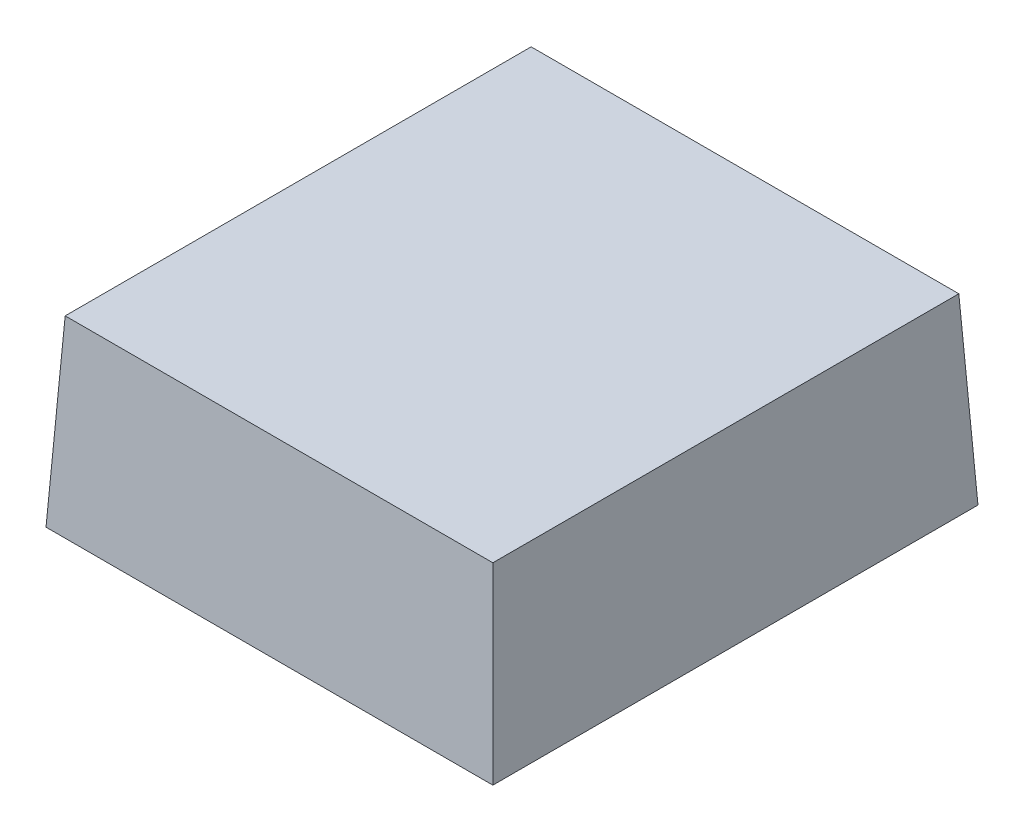
from build123d import *

# Parameters (mm, degrees)
SKETCH1_W           = 56.5
SKETCH1_H           = 61.34
BOSS_EXTRUDE1_DEPTH = 23.14
DRAFT1_ANGLE        = -3


with BuildPart() as part:
    # Sketch1 → Boss-Extrude1 (new body)
    with BuildSketch(Plane(origin=(0, 0, 0), x_dir=(1, 0, 0), z_dir=(0, 1, 0))):
        with Locations((28.25, 30.67)):
            Rectangle(SKETCH1_W, SKETCH1_H)
    extrude(amount=BOSS_EXTRUDE1_DEPTH)

    # Draft1
    draft1_faces = [part.faces().sort_by_distance(p)[0] for p in [
        (28.25, 11.57, 0),
        (0, 11.57, -30.67),
        (28.25, 11.57, -61.34),
        (56.5, 11.57, -30.67),
    ]]
    draft(draft1_faces, Plane(origin=(0, 0, 0), x_dir=(0, 0, -1), z_dir=(0, -1, 0)), DRAFT1_ANGLE)


solid = part.part
